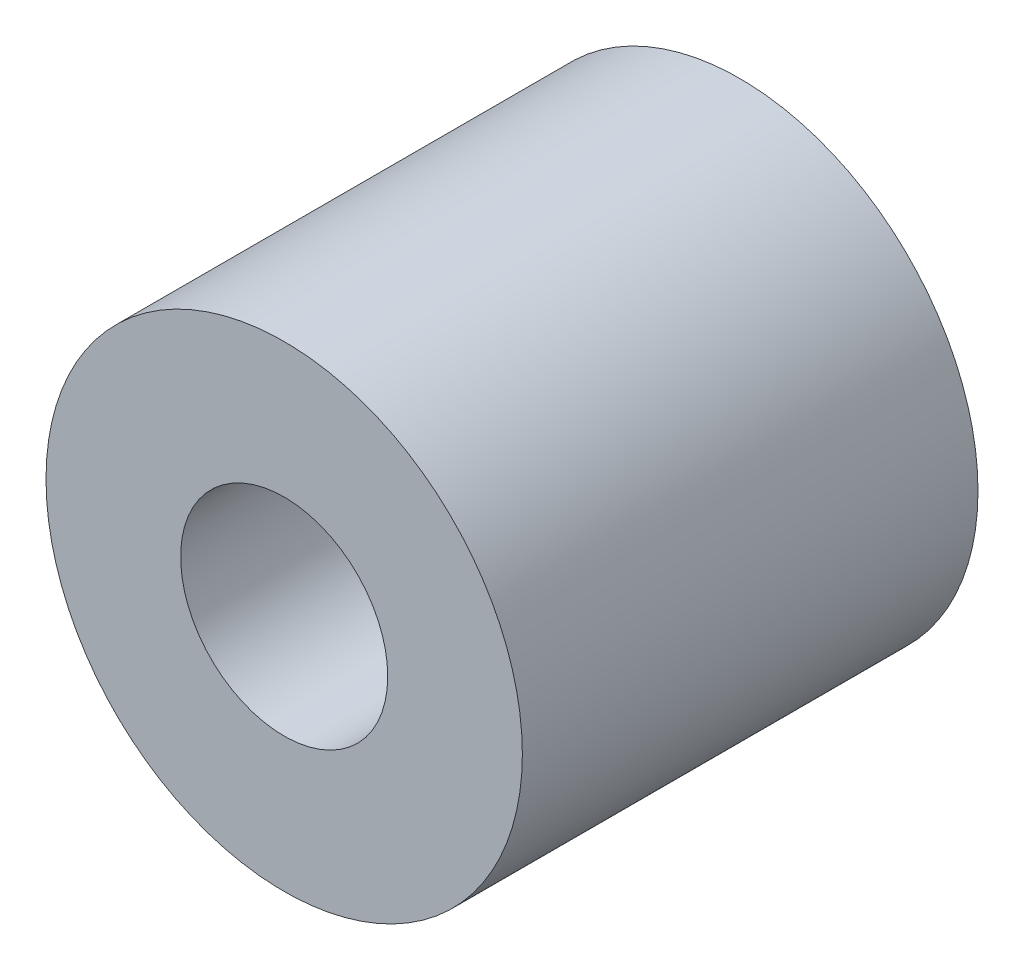
from build123d import *

# Parameters (mm, degrees)
ESQUISSE1_R        = 11.5
ESQUISSE1_R_2      = 5
BOSS_EXTRU_1_DEPTH = 22


with BuildPart() as part:
    # Esquisse1 → Boss.-Extru.1 (new body)
    with BuildSketch(Plane.XY):
        Circle(ESQUISSE1_R)
        Circle(ESQUISSE1_R_2, mode=Mode.SUBTRACT)
    extrude(amount=BOSS_EXTRU_1_DEPTH)


solid = part.part
